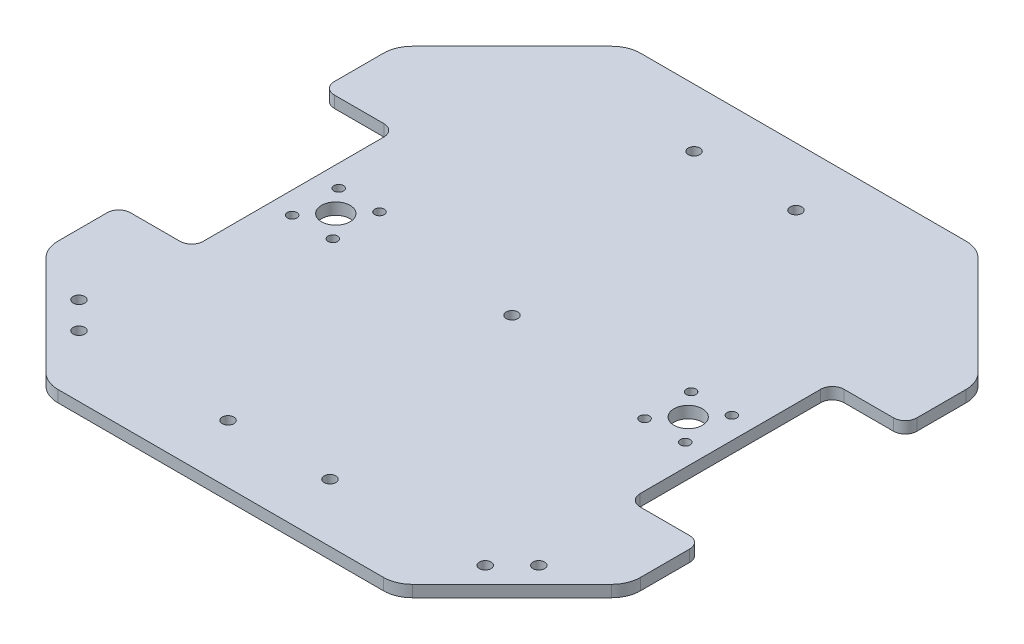
from build123d import *

# Parameters (mm, degrees)
EXTRUDE_1_DEPTH     = 4
FILLET_1_R          = 4
FILLET_2_R          = 10
SKETCH_8_R          = 4.9
SKETCH_8_R_2        = 1.65
SKETCH_8_R_3        = 2
CUT_EXTRUDE_1_DEPTH = 5


with BuildPart() as part:
    # 草图1 → 凸台-拉伸1 (new body)
    with BuildSketch(Plane(origin=(0, 0, 0), x_dir=(1, 0, 0), z_dir=(0, 1, 0))):
        Polygon((60, 100), (-60, 100), (-100, 60), (-100, 35), (-75, 35), (-75, -35), (-100, -35), (-100, -60), (-60, -100), (60, -100), (100, -60), (100, -35), (75, -35), (75, 35), (100, 35), (100, 60), align=None)
    extrude(amount=EXTRUDE_1_DEPTH)

    # 圆角1
    fillet_1_edges = [part.edges().sort_by_distance(p)[0] for p in [
        (100, 2, 35),
        (-100, 2, 35),
        (-75, 2, 35),
        (-75, 2, -35),
        (-100, 2, -35),
        (100, 2, -35),
        (75, 2, -35),
        (75, 2, 35),
    ]]
    fillet(fillet_1_edges, radius=FILLET_1_R)

    # 圆角2
    fillet_2_edges = [part.edges().sort_by_distance(p)[0] for p in [
        (100, 2, 60),
        (60, 2, 100),
        (-60, 2, 100),
        (-100, 2, 60),
        (-100, 2, -60),
        (-60, 2, -100),
        (60, 2, -100),
        (100, 2, -60),
    ]]
    fillet(fillet_2_edges, radius=FILLET_2_R)

    # 草图8 → 切除-拉伸1 (cut, through all)
    with BuildSketch(Plane(origin=(0, 4, 0), x_dir=(1, 0, 0), z_dir=(0, 1, 0))):
        with Locations((-60.5, 0)):
            Circle(SKETCH_8_R)
        with Locations((-67.5, 8)):
            Circle(SKETCH_8_R_2)
        with Locations((-53.5, 8)):
            Circle(SKETCH_8_R_2)
        with Locations((-53.5, -8)):
            Circle(SKETCH_8_R_2)
        with Locations((-67.5, -8)):
            Circle(SKETCH_8_R_2)
        with Locations((53.5, -8)):
            Circle(SKETCH_8_R_2)
        with Locations((67.5, -8)):
            Circle(SKETCH_8_R_2)
        with Locations((60.5, 0)):
            Circle(SKETCH_8_R)
        with Locations((53.5, 8)):
            Circle(SKETCH_8_R_2)
        with Locations((67.5, 8)):
            Circle(SKETCH_8_R_2)
        with Locations((-17.5, 80)):
            Circle(SKETCH_8_R_3)
        with Locations((17.5, 80)):
            Circle(SKETCH_8_R_3)
        with Locations((17.5, -80)):
            Circle(SKETCH_8_R_3)
        with Locations((-17.5, -80)):
            Circle(SKETCH_8_R_3)
        Circle(SKETCH_8_R_3)
        with Locations((-78.939339828, -69.746951673)):
            Circle(SKETCH_8_R_3)
        with Locations((-69.746951673, -78.939339828)):
            Circle(SKETCH_8_R_3)
        with Locations((69.746951673, -78.939339828)):
            Circle(SKETCH_8_R_3)
        with Locations((78.939339828, -69.746951673)):
            Circle(SKETCH_8_R_3)
    extrude(amount=-CUT_EXTRUDE_1_DEPTH, mode=Mode.SUBTRACT)


solid = part.part
